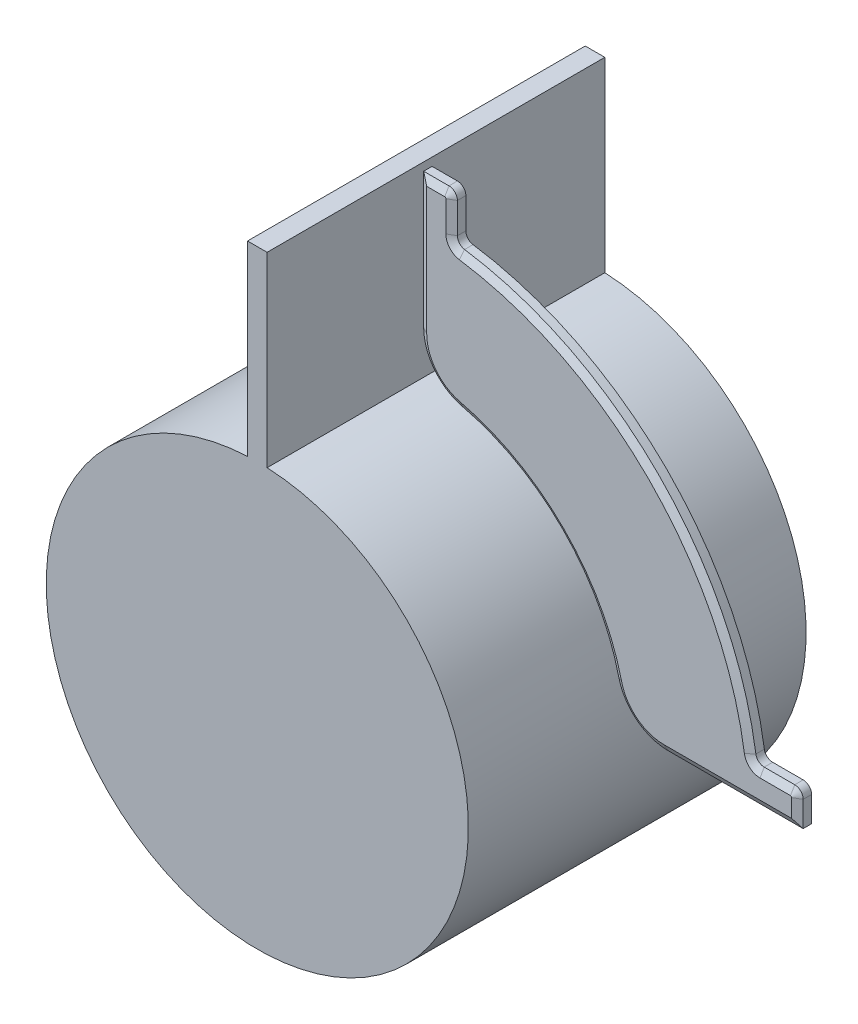
from build123d import *

# Parameters (mm, degrees)
BOSS_EXTRUDE1_DEPTH = 6.35
BOSS_EXTRUDE2_DEPTH = 63.5
CHAMFER2_SIZE       = 2.74963128
CHAMFER2_SIZE2      = 1.58750036
CHAMFER3_SIZE       = 2.74963128
CHAMFER3_SIZE2      = 1.58750036


with BuildPart() as part:
    # Sketch1 → Boss-Extrude1 (new body)
    with BuildSketch(Plane.XY):
        with BuildLine():
            ThreePointArc((3.81, 95.733489569), (7.906914495, 83.930619838), (18.435483871, 77.204427072))
            ThreePointArc((18.435483871, 77.204427072), (56.126600757, 56.126600757), (77.204427072, 18.435483871))
            ThreePointArc((77.204427072, 18.435483871), (83.930619838, 7.906914495), (95.733489569, 3.81))
            Line((95.733489569, 3.81), (146.533489569, 3.81))
            Line((146.533489569, 3.81), (146.533489569, 13.335))
            ThreePointArc((146.533489569, 13.335), (145.603553599, 15.58006403), (143.358489569, 16.51))
            Line((143.358489569, 16.51), (131.889056692, 16.51))
            ThreePointArc((131.889056692, 16.51), (129.81631301, 17.279930639), (128.748841056, 19.216309524))
            ThreePointArc((128.748841056, 19.216309524), (92.047625241, 92.047625241), (19.216309524, 128.748841056))
            ThreePointArc((19.216309524, 128.748841056), (17.279930639, 129.81631301), (16.51, 131.889056692))
            Line((16.51, 131.889056692), (16.51, 143.358489569))
            ThreePointArc((16.51, 143.358489569), (15.58006403, 145.603553599), (13.335, 146.533489569))
            Line((13.335, 146.533489569), (3.81, 146.533489569))
            Line((3.81, 146.533489569), (3.81, 95.733489569))
        make_face()
    extrude(amount=BOSS_EXTRUDE1_DEPTH)

    # Chamfer2
    chamfer2_edges = [part.edges().sort_by_distance(p)[0] for p in [
        (8.5725, 146.533489569, 0),
        (15.58006403, 145.603553599, 0),
        (16.51, 137.62377313, 0),
        (17.279930639, 129.81631301, 0),
        (92.047625241, 92.047625241, 0),
        (129.81631301, 17.279930639, 0),
        (137.62377313, 16.51, 0),
        (145.603553599, 15.58006403, 0),
        (146.533489569, 8.5725, 0),
        (121.133489569, 3.81, 0),
        (83.930619838, 7.906914495, 0),
        (56.126600757, 56.126600757, 0),
        (7.906914495, 83.930619838, 0),
        (3.81, 121.133489569, 0),
    ]]
    chamfer2_side = [part.faces().sort_by_distance(p)[0] for p in [
        (69.290156308, 69.290156308, 0),
    ]]
    chamfer(chamfer2_edges, length=CHAMFER2_SIZE, length2=CHAMFER2_SIZE2, reference=chamfer2_side[0])

    # Chamfer3
    chamfer3_edges = [part.edges().sort_by_distance(p)[0] for p in [
        (7.906914495, 83.930619838, 6.35),
        (56.126600757, 56.126600757, 6.35),
        (83.930619838, 7.906914495, 6.35),
        (121.133489569, 3.81, 6.35),
        (146.533489569, 8.5725, 6.35),
        (145.603553599, 15.58006403, 6.35),
        (137.62377313, 16.51, 6.35),
        (129.81631301, 17.279930639, 6.35),
        (92.047625241, 92.047625241, 6.35),
        (17.279930639, 129.81631301, 6.35),
        (3.81, 121.133489569, 6.35),
        (16.51, 137.62377313, 6.35),
        (15.58006403, 145.603553599, 6.35),
        (8.5725, 146.533489569, 6.35),
    ]]
    chamfer3_side = [part.faces().sort_by_distance(p)[0] for p in [
        (69.290156308, 69.290156308, 6.35),
    ]]
    chamfer(chamfer3_edges, length=CHAMFER3_SIZE, length2=CHAMFER3_SIZE2, reference=chamfer3_side[0])


with BuildPart() as body_2:
    # Sketch2 → Boss-Extrude2 (new body, symmetric)
    with BuildSketch(Plane.XY):
        with BuildLine():
            Line((3.683, 149.441811306), (-3.683, 149.441811306))
            Line((-3.683, 149.441811306), (-3.683, 79.28950836))
            ThreePointArc((-3.683, 79.28950836), (0, -79.375), (3.683, 79.28950836))
            Line((3.683, 79.28950836), (3.683, 149.441811306))
        make_face()
    extrude(amount=BOSS_EXTRUDE2_DEPTH, both=True)


solid = Compound([part.part, body_2.part])
